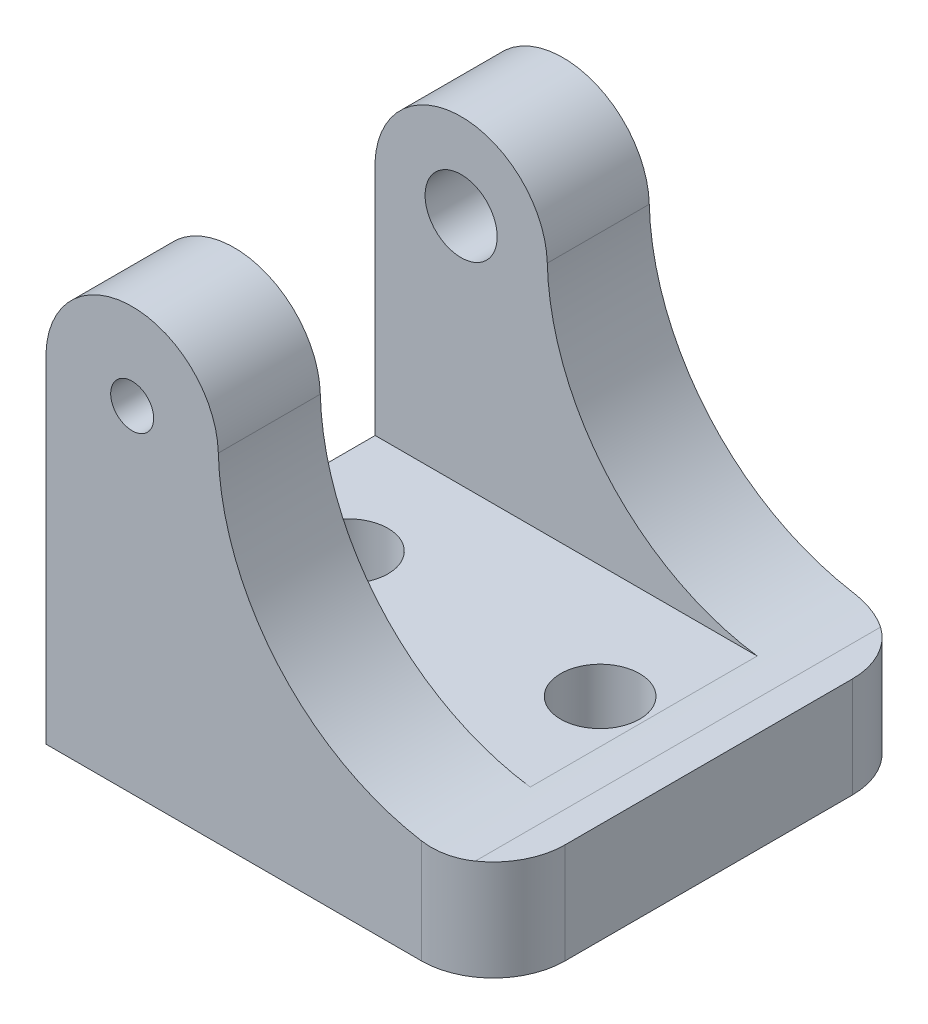
from build123d import *

# Parameters (mm, degrees)
BOSS_EXTRUDE1_DEPTH                              = 38.1
SKETCH3_W                                        = 20.066
SKETCH3_H                                        = 28.2194
CUT_EXTRUDE1_DEPTH                               = 1.021241984
CUT_EXTRUDE1_DEPTH_BACK                          = 40.5224
F_10_24_TAPPED_HOLE1_D                           = 3.7973
F_10_24_TAPPED_HOLE1_DEPTH                       = 12.954
F_10_24_TAPPED_HOLE1_TIP                         = 1.140824014
CBORE_FOR_1_4_SOCKET_SHOULDER_SCREW1_D           = 6.3754
CBORE_FOR_1_4_SOCKET_SHOULDER_SCREW1_DEPTH       = 9.017
CBORE_FOR_1_4_SOCKET_SHOULDER_SCREW1_CBORE_D     = 10.2616
CBORE_FOR_1_4_SOCKET_SHOULDER_SCREW1_CBORE_DEPTH = 3.8862
SKETCH13_R                                       = 3.4925
CUT_EXTRUDE2_DEPTH                               = 38.322374195
FILLET1_R                                        = 6.35


with BuildPart() as part:
    # Sketch1 → Boss-Extrude1 (new body)
    with BuildSketch(Plane.XY):
        with BuildLine():
            Line((-19.7612, 0), (19.7612, 0))
            Line((19.7612, 0), (19.7612, 8.89))
            Line((19.7612, 8.89), (17.037205242, 8.89))
            ThreePointArc((17.037205242, 8.89), (1.975351394, 15.011688564), (-4.545142708, 29.905233101))
            ThreePointArc((-4.545142708, 29.905233101), (-12.548269927, 37.3126), (-19.7612, 29.1338))
            Line((-19.7612, 29.1338), (-19.7612, 0))
        make_face()
    extrude(amount=-BOSS_EXTRUDE1_DEPTH)

    # Sketch3 → Cut-Extrude1 (cut, two sides)
    with BuildSketch(Plane.ZY.offset(19.7612)) as cut_extrude1_sk:
        with Locations((-19.05, 23.212674195)):
            Rectangle(SKETCH3_W, SKETCH3_H)
    extrude(amount=CUT_EXTRUDE1_DEPTH, mode=Mode.SUBTRACT)
    extrude(cut_extrude1_sk.sketch, amount=-CUT_EXTRUDE1_DEPTH_BACK, mode=Mode.SUBTRACT)

    # #10-24 Tapped Hole1
    with Locations(Plane.XY):
        with Locations((-12.162441984, 29.702374195)):
            Hole(F_10_24_TAPPED_HOLE1_D / 2, depth=F_10_24_TAPPED_HOLE1_DEPTH)
            with Locations((0, 0, -(F_10_24_TAPPED_HOLE1_DEPTH + F_10_24_TAPPED_HOLE1_TIP / 2))):  # 118° drill point
                Cone(0, F_10_24_TAPPED_HOLE1_D / 2, F_10_24_TAPPED_HOLE1_TIP, mode=Mode.SUBTRACT)

    # CBORE for 1/4 Socket Shoulder Screw1
    with Locations(Plane(origin=(0, 0, -38.1), x_dir=(-1, 0, 0), z_dir=(0, 0, -1))):
        with Locations((12.162441984, 29.702374195)):
            CounterBoreHole(CBORE_FOR_1_4_SOCKET_SHOULDER_SCREW1_D / 2, CBORE_FOR_1_4_SOCKET_SHOULDER_SCREW1_CBORE_D / 2, CBORE_FOR_1_4_SOCKET_SHOULDER_SCREW1_CBORE_DEPTH, depth=CBORE_FOR_1_4_SOCKET_SHOULDER_SCREW1_DEPTH)

    # Sketch13 → Cut-Extrude2 (cut, through all)
    with BuildSketch(Plane.XZ):
        with Locations((-12.0904, -19.05)):
            Circle(SKETCH13_R)
        with Locations((10.16, -19.05)):
            Circle(SKETCH13_R)
    extrude(amount=-CUT_EXTRUDE2_DEPTH, mode=Mode.SUBTRACT)

    # Fillet1
    fillet1_edges = [part.edges().sort_by_distance(p)[0] for p in [
        (19.7612, 4.445, -38.1),
        (19.7612, 4.445, 0),
    ]]
    fillet(fillet1_edges, radius=FILLET1_R)


solid = part.part
